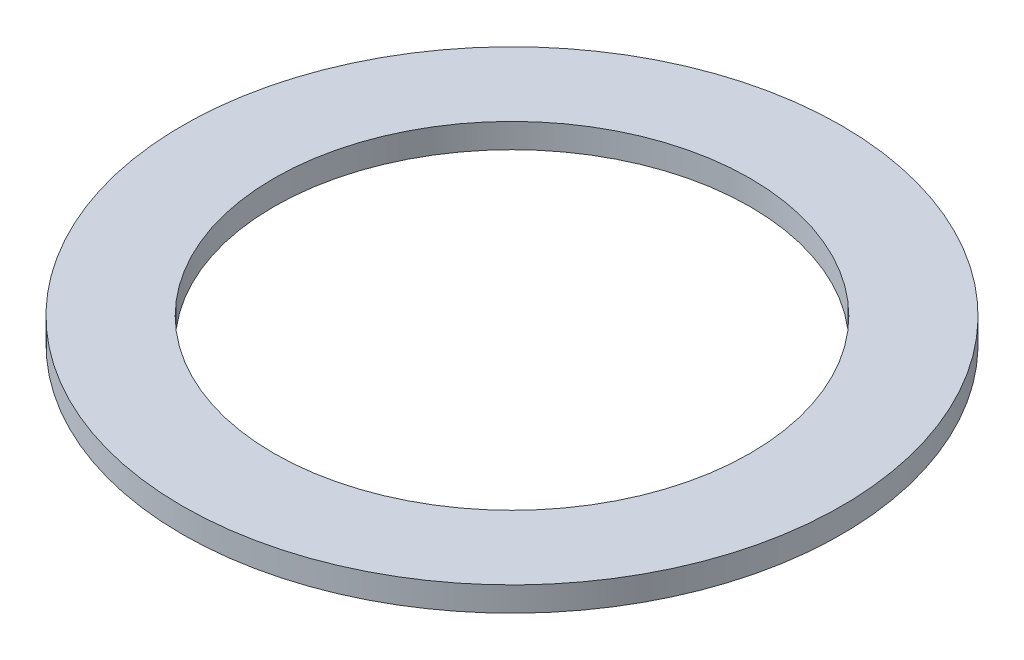
from build123d import *

# Parameters (mm, degrees)
SKETCH1_W = 7.4803
SKETCH1_H = 2.0066


with BuildPart() as part:
    # Sketch1 → Revolve1 (revolve)
    with BuildSketch(Plane.XY):
        with Locations((23.23465, 1.0033)):
            Rectangle(SKETCH1_W, SKETCH1_H)
    revolve(axis=Axis((0, 0.195231469, 0), (0, 1, 0)))


solid = part.part
